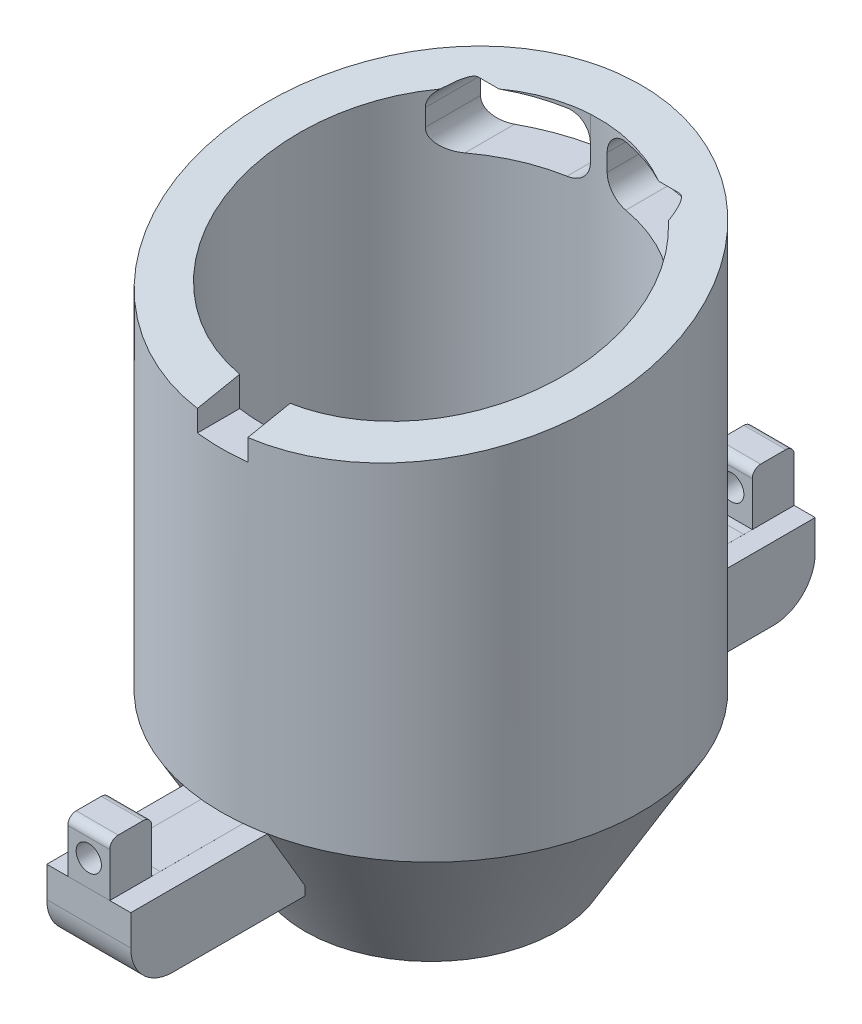
from build123d import *

# Parameters (mm, degrees)
SKETCH1_R                  = 4.9995
SKETCH1_R_2                = 4.0005
BOSS_EXTRUDE1_DEPTH        = 10
SKETCH2_R                  = 5
BOSS_EXTRUDE2_DEPTH        = 5
BOSS_EXTRUDE2_DRAFT        = -30
SKETCH3_R                  = 4
CUT_EXTRUDE1_DEPTH         = 5
CUT_EXTRUDE1_DRAFT         = -30
CUT_EXTRUDE6_DEPTH         = 0.301
CUT_EXTRUDE6_DEPTH_BACK    = 0.301
SKETCH10_R                 = 0.2005
CUT_EXTRUDE9_DEPTH         = 0.5
CUT_EXTRUDE9_DEPTH_BACK    = 0.5
CUT_EXTRUDE10_DEPTH        = 6
CUT_EXTRUDE10_DEPTH_BACK   = 6
CUT_EXTRUDE13_DEPTH        = 6
SKETCH14_W                 = 9.766449239
SKETCH14_H                 = 2.017046323
CUT_EXTRUDE14_DEPTH        = 6
CUT_EXTRUDE14_DEPTH_BACK   = 6
BOSS_EXTRUDE3_DEPTH        = 1
BOSS_EXTRUDE3_DEPTH_BACK   = 1
BOSS_EXTRUDE3_2_DEPTH      = 1
BOSS_EXTRUDE3_2_DEPTH_BACK = 1
SKETCH18_W                 = 1.2
SKETCH18_H                 = 1.068876387
CUT_EXTRUDE15_DEPTH        = 9.150724798
CUT_EXTRUDE16_START        = -13.149942
SKETCH19_W                 = 0.5
SKETCH19_H                 = 1.05
CUT_EXTRUDE16_DEPTH        = 13.150225
CUT_EXTRUDE17_START        = -13.150442
SKETCH20_W                 = 0.5
SKETCH20_H                 = 1.05
CUT_EXTRUDE17_DEPTH        = 13.150725
SKETCH22_R                 = 0.3005
CUT_EXTRUDE19_DEPTH        = 0.999
SKETCH24_R                 = 0.3
CUT_EXTRUDE20_DEPTH        = 0.999
CUT_EXTRUDE21_DEPTH        = 0.501
CUT_EXTRUDE21_DEPTH_BACK   = 0.501


with BuildPart() as part:
    # Sketch1 → Boss-Extrude1 (new body)
    with BuildSketch(Plane(origin=(0, 0, 0), x_dir=(1, 0, 0), z_dir=(0, 1, 0))):
        with Locations(Location((0, 0, 0), (0, 0, 270))):  # turned: the seam where the file's is
            Circle(SKETCH1_R)
        with Locations(Location((0, 0, 0), (0, 0, 270))):  # turned: the seam where the file's is
            Circle(SKETCH1_R_2, mode=Mode.SUBTRACT)
    extrude(amount=BOSS_EXTRUDE1_DEPTH)


with BuildPart() as boss_extrude2_tool:
    # Sketch2 → Boss-Extrude2 (with draft: the straight prism first)
    with BuildSketch(Plane(origin=(0, 0, 0), x_dir=(1, 0, 0), z_dir=(0, 1, 0))):
        Circle(SKETCH2_R)
    extrude(amount=-BOSS_EXTRUDE2_DEPTH)
    # Boss-Extrude2: the draft: its side faces are tilted about the plane it starts from
    boss_extrude2_sides = [boss_extrude2_tool.faces().sort_by_distance(p)[0] for p in [
        (-5, -2.5, 0),
    ]]
    draft(boss_extrude2_sides, Plane(origin=(0, 0, 0), x_dir=(1, 0, 0), z_dir=(0, 1, 0)), BOSS_EXTRUDE2_DRAFT)


with BuildPart() as part_1:
    add(part.part)

    # Boss-Extrude2: add boss_extrude2_tool
    add(boss_extrude2_tool.part)


with BuildPart() as cut_extrude1_tool:
    # Sketch3 → Cut-Extrude1 (with draft: the straight prism first)
    with BuildSketch(Plane(origin=(0, 0, 0), x_dir=(1, 0, 0), z_dir=(0, 1, 0))):
        Circle(SKETCH3_R)
    extrude(amount=-CUT_EXTRUDE1_DEPTH)
    # Cut-Extrude1: the draft: its side faces are tilted about the plane it starts from
    cut_extrude1_sides = [cut_extrude1_tool.faces().sort_by_distance(p)[0] for p in [
        (-4, -2.5, 0),
    ]]
    draft(cut_extrude1_sides, Plane(origin=(0, 0, 0), x_dir=(1, 0, 0), z_dir=(0, 1, 0)), CUT_EXTRUDE1_DRAFT)


with BuildPart() as part_2:
    add(part_1.part)

    # Cut-Extrude1: cut by cut_extrude1_tool
    add(cut_extrude1_tool.part, mode=Mode.SUBTRACT)

    # Sketch9 → Cut-Extrude6 (cut, two sides)
    with BuildSketch(Plane(origin=(0, 0, 0), x_dir=(0, 0, -1), z_dir=(1, 0, 0))) as cut_extrude6_sk:
        with BuildLine():
            Line((-2.931624327, -3.016506351), (-2.258419246, -3.016506351))
            Line((-2.258419246, -3.016506351), (-2.305810355, -2.700813972))
            Line((-2.305810355, -2.700813972), (-2.605810355, -2.18119873))
            Line((-2.605810355, -2.18119873), (-3.232124327, -1.157671827))
            Line((-3.232124327, -1.157671827), (-3.232124327, -2.716006351))
            ThreePointArc((-3.232124327, -2.716006351), (-3.144109915, -2.928491939), (-2.931624327, -3.016506351))
        make_face()
    extrude(amount=CUT_EXTRUDE6_DEPTH, mode=Mode.SUBTRACT)
    extrude(cut_extrude6_sk.sketch, amount=-CUT_EXTRUDE6_DEPTH_BACK, mode=Mode.SUBTRACT)

    # Sketch10 → Cut-Extrude9 (cut, two sides)
    with BuildSketch(Plane(origin=(0, 0, 0), x_dir=(0, 0, -1), z_dir=(1, 0, 0))) as cut_extrude9_sk:
        with Locations((-2.931624327, -2.716006351)):
            Circle(SKETCH10_R)
    extrude(amount=CUT_EXTRUDE9_DEPTH, mode=Mode.SUBTRACT)
    extrude(cut_extrude9_sk.sketch, amount=-CUT_EXTRUDE9_DEPTH_BACK, mode=Mode.SUBTRACT)

    # Sketch11 → Cut-Extrude10 (cut, two sides)
    with BuildSketch(Plane(origin=(0, 0, 0), x_dir=(0, 0, -1), z_dir=(1, 0, 0))) as cut_extrude10_sk:
        Polygon((-6.255560267, 7.748887947), (6.541927726, 10.308385545), (-6.255560267, 10.308385545), align=None)
    extrude(amount=CUT_EXTRUDE10_DEPTH, mode=Mode.SUBTRACT)
    extrude(cut_extrude10_sk.sketch, amount=-CUT_EXTRUDE10_DEPTH_BACK, mode=Mode.SUBTRACT)

    # Sketch12 → Cut-Extrude13 (cut, through all)
    with BuildSketch(Plane.XY):
        with BuildLine():
            Line((2.896053459, 8.796016707), (2.896053459, 9.203983293))
            ThreePointArc((2.896053459, 9.203983293), (2.74960685, 9.557536684), (2.396053459, 9.703983293))
            Line((2.396053459, 9.703983293), (0.7, 9.703983293))
            ThreePointArc((0.7, 9.703983293), (0.346446609, 9.557536684), (0.2, 9.203983293))
            Line((0.2, 9.203983293), (0.2, 8.796016707))
            ThreePointArc((0.2, 8.796016707), (0.346446609, 8.442463316), (0.7, 8.296016707))
            Line((0.7, 8.296016707), (2.396053459, 8.296016707))
            ThreePointArc((2.396053459, 8.296016707), (2.74960685, 8.442463316), (2.896053459, 8.796016707))
        make_face()
        with BuildLine():
            Line((-2.896053459, 8.796016707), (-2.896053459, 9.203983293))
            ThreePointArc((-2.896053459, 9.203983293), (-2.74960685, 9.557536684), (-2.396053459, 9.703983293))
            Line((-2.396053459, 9.703983293), (-0.7, 9.703983293))
            ThreePointArc((-0.7, 9.703983293), (-0.346446609, 9.557536684), (-0.2, 9.203983293))
            Line((-0.2, 9.203983293), (-0.2, 8.796016707))
            ThreePointArc((-0.2, 8.796016707), (-0.346446609, 8.442463316), (-0.7, 8.296016707))
            Line((-0.7, 8.296016707), (-2.396053459, 8.296016707))
            ThreePointArc((-2.396053459, 8.296016707), (-2.74960685, 8.442463316), (-2.896053459, 8.796016707))
        make_face()
    extrude(amount=-CUT_EXTRUDE13_DEPTH, mode=Mode.SUBTRACT)

    # Sketch14 → Cut-Extrude14 (cut, two sides)
    with BuildSketch(Plane(origin=(0, 0, 0), x_dir=(0, 0, -1), z_dir=(1, 0, 0))) as cut_extrude14_sk:
        with Locations((-0.116775381, -4.468773181)):
            Rectangle(SKETCH14_W, SKETCH14_H)
    extrude(amount=CUT_EXTRUDE14_DEPTH, mode=Mode.SUBTRACT)
    extrude(cut_extrude14_sk.sketch, amount=-CUT_EXTRUDE14_DEPTH_BACK, mode=Mode.SUBTRACT)

    # Sketch18 → Cut-Extrude15 (cut, through all)
    with BuildSketch(Plane.XY):
        with Locations((0, 8.034538194)):
            Rectangle(SKETCH18_W, SKETCH18_H)
    extrude(amount=CUT_EXTRUDE15_DEPTH, mode=Mode.SUBTRACT)

    # Sketch26 → Cut-Extrude21 (cut, two sides)
    with BuildSketch(Plane(origin=(0, 0, 0), x_dir=(0, 0, -1), z_dir=(1, 0, 0))) as cut_extrude21_sk:
        with BuildLine():
            Line((-2.931624327, -2.416006351), (-3.232124327, -2.416006351))
            Line((-3.232124327, -2.416006351), (-3.232124327, -0.963843284))
            Line((-3.232124327, -0.963843284), (-1.865300653, -0.963843284))
            Line((-1.865300653, -0.963843284), (-1.865300653, -3.016006351))
            Line((-1.865300653, -3.016006351), (-2.631624327, -3.016365681))
            Line((-2.631624327, -3.016365681), (-2.631624327, -2.716006351))
            ThreePointArc((-2.631624327, -2.716006351), (-2.719492293, -2.503874317), (-2.931624327, -2.416006351))
        make_face()
    extrude(amount=CUT_EXTRUDE21_DEPTH, mode=Mode.SUBTRACT)
    extrude(cut_extrude21_sk.sketch, amount=-CUT_EXTRUDE21_DEPTH_BACK, mode=Mode.SUBTRACT)


with BuildPart() as body_2:
    # Sketch15 → Boss-Extrude3 (new body, two sides)
    with BuildSketch(Plane(origin=(0, 0, 0), x_dir=(0, 0, -1), z_dir=(1, 0, 0))) as boss_extrude3_sk:
        with BuildLine():
            Line((-4.000442184, -0.000306746), (-4.00111186, -1.73012501))
            Line((-4.00111186, -1.73012501), (-7.151111935, -1.728905528))
            ThreePointArc((-7.151111935, -1.728905528), (-7.858105273, -1.435738585), (-8.150724723, -0.728518467))
            Line((-8.150724723, -0.728518467), (-8.150442065, 0.001606846))
            Line((-8.150442065, 0.001606846), (-8.150442065, 1.051606846))
            ThreePointArc((-8.150442065, 1.051606846), (-8.091863421, 1.193028202), (-7.950442065, 1.251606846))
            Line((-7.950442065, 1.251606846), (-7.351442065, 1.251606846))
            ThreePointArc((-7.351442065, 1.251606846), (-7.210020708, 1.193028202), (-7.151442065, 1.051606846))
            Line((-7.151442065, 1.051606846), (-7.151442065, 0.20083571))
            Line((-7.151442065, 0.20083571), (-7.151442065, 0.000835725))
            Line((-7.151442065, 0.000835725), (-6.951519492, 0.000835725))
            Line((-6.951519492, 0.000835725), (-4.000442184, -0.000306746))
        make_face()
    extrude(amount=BOSS_EXTRUDE3_DEPTH)
    extrude(boss_extrude3_sk.sketch, amount=-BOSS_EXTRUDE3_DEPTH_BACK)

    # Sketch19 → Cut-Extrude16 (cut)
    with BuildSketch(Plane.XY.offset(8.150442065).offset(CUT_EXTRUDE16_START)):
        with Locations((-0.75, 0.526606846)):
            Rectangle(SKETCH19_W, SKETCH19_H)
        with Locations((0.75, 0.526606846)):
            Rectangle(SKETCH19_W, SKETCH19_H)
        Polygon((-1, 1.051606846), (-0.5, 1.051606846), (-0.5, 2.101606846), (-1.497228445, 2.101606846), (-1.497228445, 0), (-0.5, 0), (-0.5, 0.001606846), (-1, 0.001606846), align=None)
        Polygon((1.705190103, 2.101606846), (0.5, 2.101606846), (0.5, 1.051606846), (1, 1.051606846), (1, 0.001606846), (0.5, 0.001606846), (0.5, 0), (1.705190103, 0), align=None)
    extrude(amount=CUT_EXTRUDE16_DEPTH, mode=Mode.SUBTRACT)

    # Sketch22 → Cut-Extrude19 (cut)
    with BuildSketch(Plane.XY.offset(7.151442065)):
        with Locations((0, 0.626606618)):
            Circle(SKETCH22_R)
    extrude(amount=CUT_EXTRUDE19_DEPTH, mode=Mode.SUBTRACT)


with BuildPart() as body_3:
    # Sketch15 → Boss-Extrude3 2 (new body, two sides)
    with BuildSketch(Plane(origin=(0, 0, 0), x_dir=(0, 0, -1), z_dir=(1, 0, 0))) as boss_extrude3_2_sk:
        with BuildLine():
            Line((7.151442065, 1.051606846), (7.151442065, 0.20083571))
            Line((7.151442065, 0.20083571), (7.151442065, 0.000835725))
            Line((7.151442065, 0.000835725), (6.951519492, 0.000835725))
            Line((6.951519492, 0.000835725), (4.000442184, -0.000306746))
            Line((4.000442184, -0.000306746), (4.00111186, -1.73012501))
            Line((4.00111186, -1.73012501), (7.151111935, -1.728905528))
            ThreePointArc((7.151111935, -1.728905528), (7.858105273, -1.435738585), (8.150724723, -0.728518467))
            Line((8.150724723, -0.728518467), (8.150442065, 0.001606846))
            Line((8.150442065, 0.001606846), (8.150442065, 1.051606846))
            ThreePointArc((8.150442065, 1.051606846), (8.091863421, 1.193028202), (7.950442065, 1.251606846))
            Line((7.950442065, 1.251606846), (7.351442065, 1.251606846))
            ThreePointArc((7.351442065, 1.251606846), (7.210020708, 1.193028202), (7.151442065, 1.051606846))
        make_face()
    extrude(amount=BOSS_EXTRUDE3_2_DEPTH)
    extrude(boss_extrude3_2_sk.sketch, amount=-BOSS_EXTRUDE3_2_DEPTH_BACK)

    # Sketch20 → Cut-Extrude17 (cut)
    with BuildSketch(Plane(origin=(0, 0, -8.150442065), x_dir=(-1, 0, 0), z_dir=(0, 0, -1)).offset(CUT_EXTRUDE17_START)):
        with Locations((-0.75, 0.526606846)):
            Rectangle(SKETCH20_W, SKETCH20_H)
        with Locations((0.75, 0.526606846)):
            Rectangle(SKETCH20_W, SKETCH20_H)
        Polygon((0.5, 2.102586695), (0.5, 1.051606846), (1, 1.051606846), (1, 0.001606846), (0.5, 0.001606846), (0.5, 0.000626541), (0.5, 0), (1.393428378, 0), (1.393428378, 2.102586695), align=None)
        Polygon((-0.5, 1.051606846), (-0.5, 2.102586695), (-1.402882221, 2.102586695), (-1.402882221, 0), (-0.5, 0), (-0.5, 0.000626541), (-0.5, 0.001606846), (-1, 0.001606846), (-1, 1.051606846), align=None)
    extrude(amount=CUT_EXTRUDE17_DEPTH, mode=Mode.SUBTRACT)

    # Sketch24 → Cut-Extrude20 (cut)
    with BuildSketch(Plane(origin=(0, 0, -8.150442065), x_dir=(-1, 0, 0), z_dir=(0, 0, -1))):
        with Locations(Location((0, 0.626606618, 0), (0, 0, 90))):  # turned: the seam where the file's is
            Circle(SKETCH24_R)
    extrude(amount=-CUT_EXTRUDE20_DEPTH, mode=Mode.SUBTRACT)


solid = Compound([part_2.part, body_2.part, body_3.part])
